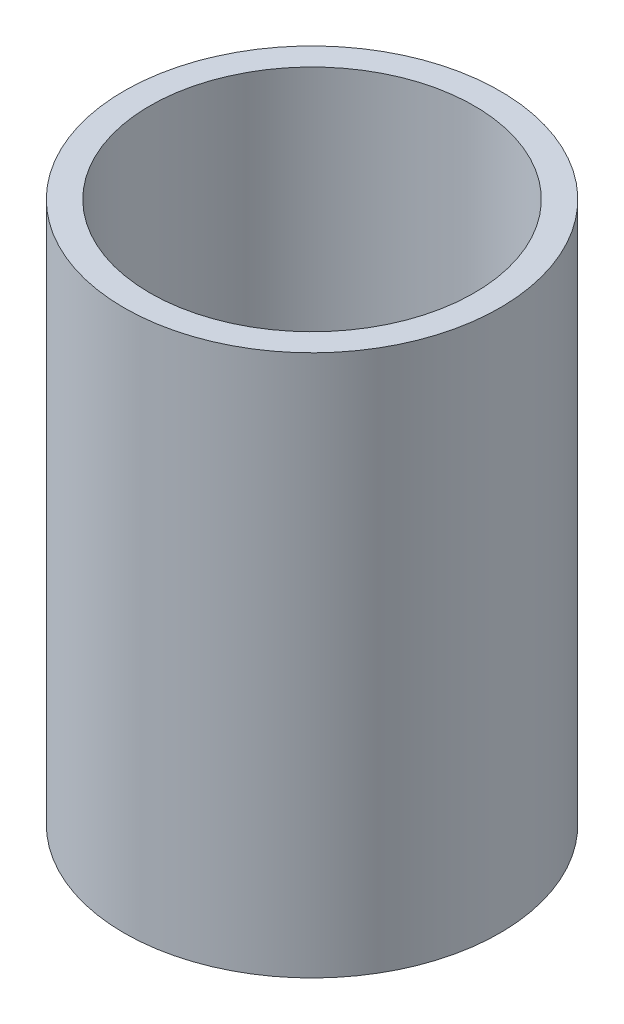
from build123d import *

# Parameters (mm, degrees)
SKETCH1_W = 6.35
SKETCH1_H = 133.35


with BuildPart() as part:
    # Sketch1 → Revolve1 (revolve)
    with BuildSketch(Plane.XY):
        with Locations((-43.11015, -21.057365567)):
            Rectangle(SKETCH1_W, SKETCH1_H)
    revolve(axis=Axis((0, 55, 0), (0, -1, 0)))


solid = part.part
